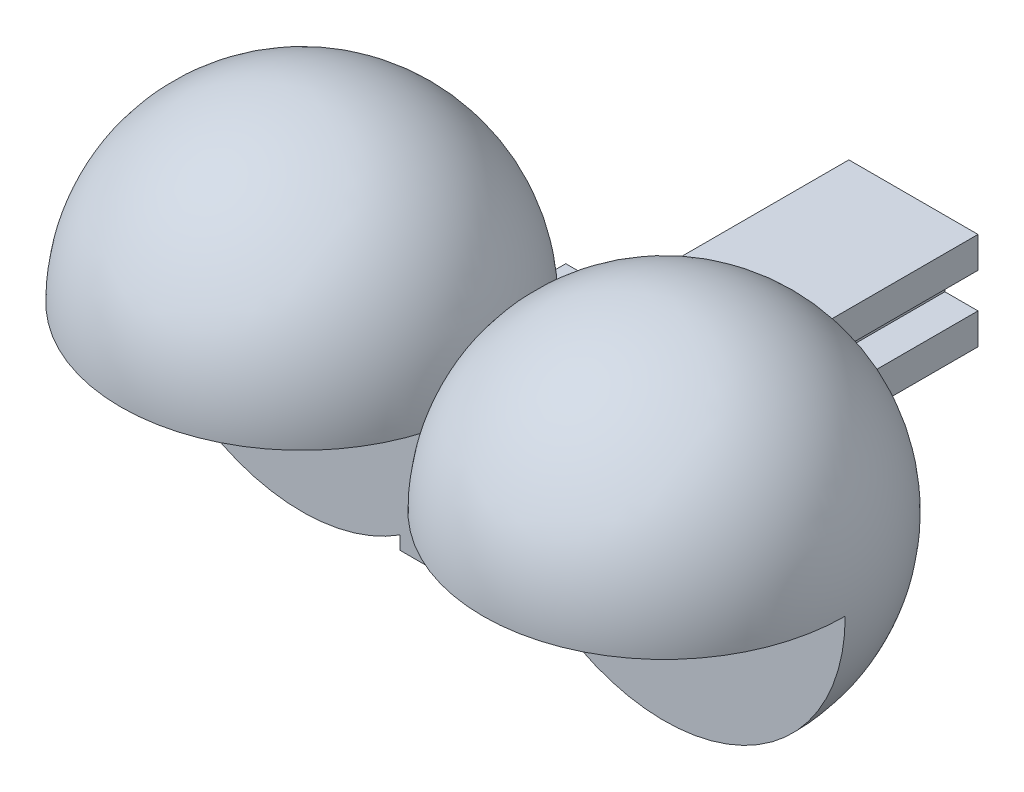
from build123d import *
from build123d.topology import SkipClean

# Parameters (mm, degrees)
SKETCH5_W           = 131.802923383
SKETCH5_H           = 32.361272333
CUT_EXTRUDE2_DEPTH  = 27.35
SKETCH7_W           = 25
SKETCH7_H           = 25
BOSS_EXTRUDE1_DEPTH = 40
CUT_EXTRUDE3_START  = -55
SKETCH8_W           = 25
SKETCH8_H           = 25
CUT_EXTRUDE3_DEPTH  = 30
BOSS_EXTRUDE3_START = -40
BOSS_EXTRUDE3_DEPTH = 25
SKETCH10_W          = 6
SKETCH10_H          = 6
CUT_EXTRUDE4_DEPTH  = 25


with BuildPart() as part:
    # Sketch1 → Revolve1 (revolve)
    with BuildSketch(Plane.XY):
        with BuildLine():
            Line((-54.7, 0), (0, 0))
            ThreePointArc((0, 0), (-27.35, 27.35), (-54.7, 0))
        make_face()
        with BuildLine():
            ThreePointArc((0, 0), (27.35, 27.35), (54.7, 0))
            Line((54.7, 0), (0, 0))
        make_face()
    revolve(axis=Axis((0, 0, 0), (1, 0, 0)))

    # Sketch5 → Cut-Extrude2 (cut)
    with SkipClean():  # the faces are left unmerged after this step: merging them gives an invalid solid
        with BuildSketch(Plane(origin=(0, 0, 0), x_dir=(1, 0, 0), z_dir=(0, 1, 0))):
            with Locations((7.898744067, -16.180636167)):
                Rectangle(SKETCH5_W, SKETCH5_H)
        extrude(amount=-CUT_EXTRUDE2_DEPTH, mode=Mode.SUBTRACT)

    # Sketch6 → Revolve2 (revolve)
    with BuildSketch(Plane.XY):
        with BuildLine():
            Line((-42.35, 0), (-12.35, 0))
            ThreePointArc((-12.35, 0), (-27.35, 15), (-42.35, 0))
        make_face()
        with BuildLine():
            ThreePointArc((12.35, 0), (27.35, 15), (42.35, 0))
            Line((42.35, 0), (12.35, 0))
        make_face()
    revolve(axis=Axis((-88.182993462, 0, 0), (1, 0, 0)))

    # Sketch7 → Boss-Extrude1 (add)
    with BuildSketch(Plane.XY):
        with Locations((0, -12.5)):
            Rectangle(SKETCH7_W, SKETCH7_H)
    extrude(amount=-BOSS_EXTRUDE1_DEPTH)

    # Sketch8 → Cut-Extrude3 (cut)
    with BuildSketch(Plane.XY.offset(CUT_EXTRUDE3_START)):
        with Locations((0, -12.5)):
            Rectangle(SKETCH8_W, SKETCH8_H)
        Polygon((9.75, -5.047227516), (-9.75, -5.047227516), (-9.75, -9.747227516), (-4.75, -9.747227516), (-4.75, -15.047227516), (-9.75, -15.047227516), (-9.75, -19.747227516), (9.75, -19.747227516), (9.75, -15.047227516), (4.75, -15.047227516), (4.75, -9.747227516), (9.75, -9.747227516), align=None, mode=Mode.SUBTRACT)
    extrude(amount=CUT_EXTRUDE3_DEPTH, mode=Mode.SUBTRACT)

    # Sketch9 → Boss-Extrude3 (add)
    with BuildSketch(Plane.XY.offset(BOSS_EXTRUDE3_START)):
        Polygon((9.75, -5.047227516), (9.75, -9.747227516), (4.75, -9.747227516), (4.75, -15.047227516), (9.75, -15.047227516), (9.75, -19.747227516), (-9.75, -19.747227516), (-9.75, -15.047227516), (-4.75, -15.047227516), (-4.75, -9.747227516), (-9.75, -9.747227516), (-9.75, -5.047227516), align=None)
    extrude(amount=-BOSS_EXTRUDE3_DEPTH)

    # Sketch10 → Cut-Extrude4 (cut)
    with BuildSketch(Plane.XY):
        with Locations((4, -15.725025673)):
            Rectangle(SKETCH10_W, SKETCH10_H)
        with Locations((-4, -15.725025673)):
            Rectangle(SKETCH10_W, SKETCH10_H)
    extrude(amount=-CUT_EXTRUDE4_DEPTH, mode=Mode.SUBTRACT)


solid = part.part
